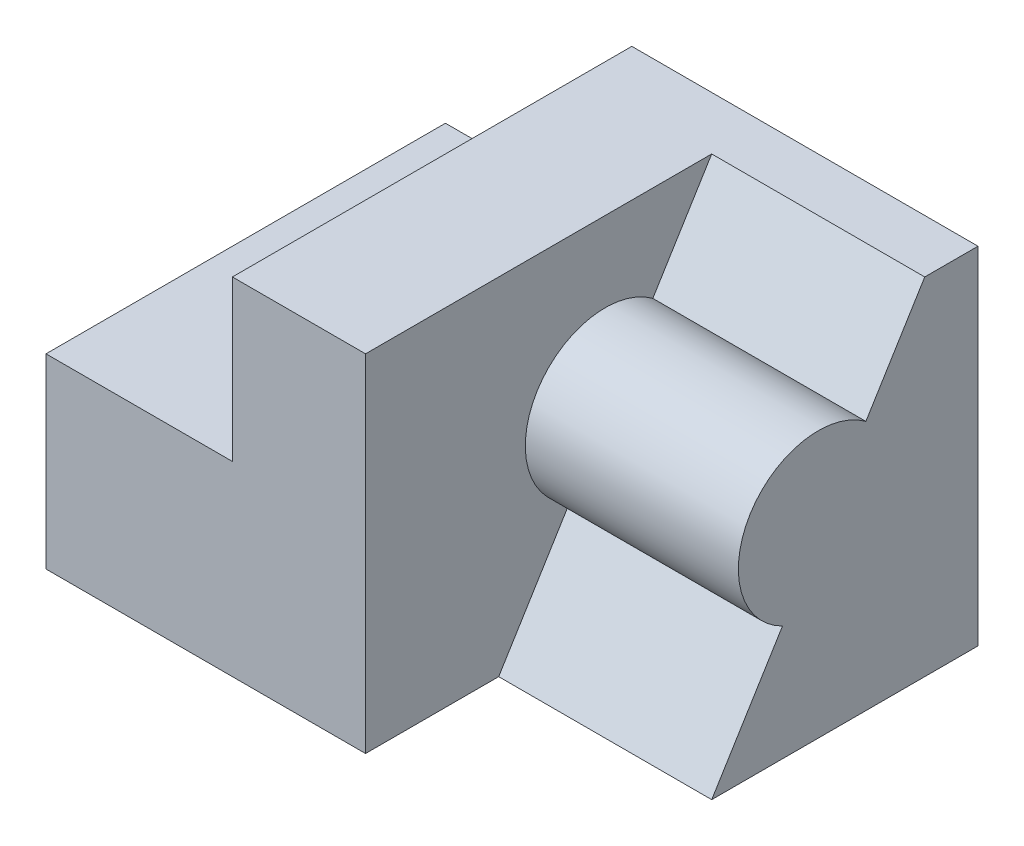
from build123d import *

# Parameters (mm, degrees)
SKETCH1_W           = 100
SKETCH1_H           = 75
BOSS_EXTRUDE1_DEPTH = 65
SKETCH2_W           = 35
SKETCH2_H           = 75
CUT_EXTRUDE1_DEPTH  = 30
CUT_EXTRUDE2_DEPTH  = 40


with BuildPart() as part:
    # Sketch1 → Boss-Extrude1 (new body)
    with BuildSketch(Plane(origin=(0, 0, 0), x_dir=(1, 0, 0), z_dir=(0, 1, 0))):
        with Locations((50, 37.5)):
            Rectangle(SKETCH1_W, SKETCH1_H)
    extrude(amount=BOSS_EXTRUDE1_DEPTH)

    # Sketch2 → Cut-Extrude1 (cut)
    with BuildSketch(Plane(origin=(0, 65, 0), x_dir=(1, 0, 0), z_dir=(0, 1, 0))):
        with Locations((17.5, 37.5)):
            Rectangle(SKETCH2_W, SKETCH2_H)
    extrude(amount=-CUT_EXTRUDE1_DEPTH, mode=Mode.SUBTRACT)

    # Sketch3 → Cut-Extrude2 (cut)
    with BuildSketch(Plane(origin=(100, 0, 0), x_dir=(0, 0, -1), z_dir=(1, 0, 0))):
        with BuildLine():
            Line((25, 0), (38.28446714, 21.587259102))
            ThreePointArc((38.28446714, 21.587259102), (32.225125249, 42.861461385), (53.947292517, 47.03935034))
            Line((53.947292517, 47.03935034), (65, 65))
            Line((65, 65), (0, 65))
            Line((0, 65), (0, 0))
            Line((0, 0), (25, 0))
        make_face()
    extrude(amount=-CUT_EXTRUDE2_DEPTH, mode=Mode.SUBTRACT)


solid = part.part
